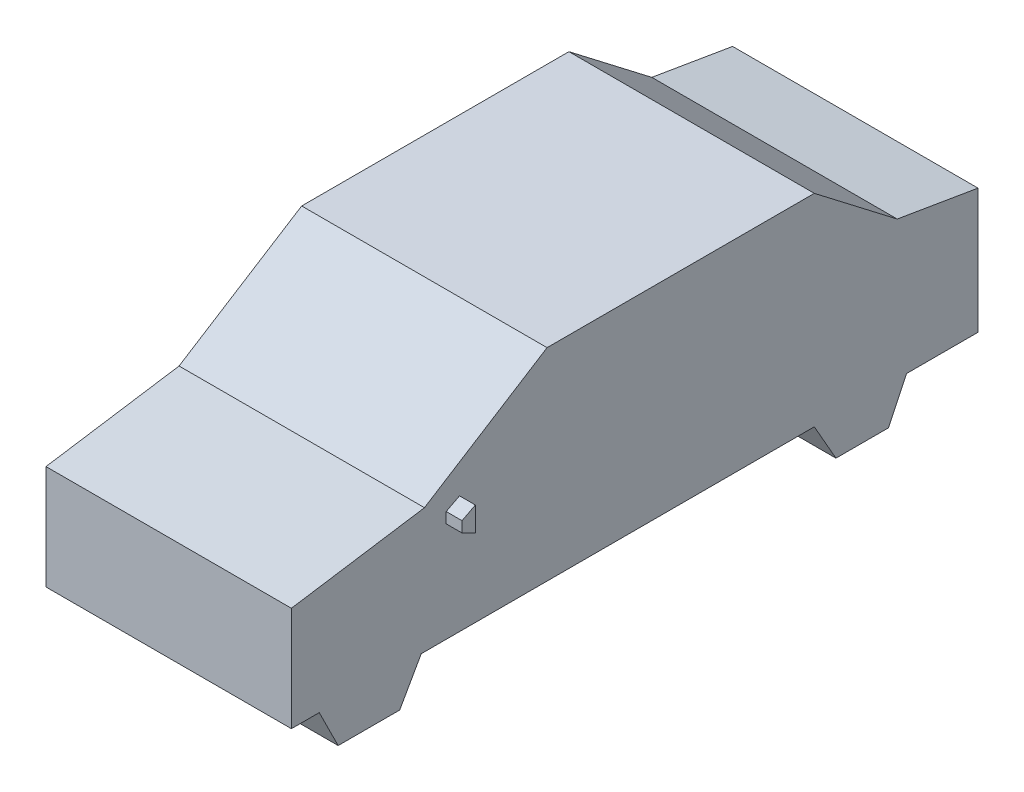
from build123d import *

# Parameters (mm, degrees)
EXTRUDE_1_DEPTH      = 1550
EXTRUDE_2_DEPTH      = 100
EXTRUDE_2_DEPTH_BACK = 1650


with BuildPart() as part:
    # Эскиз1 → Бобышка-Вытянуть1 (new body)
    with BuildSketch(Plane(origin=(0, 0, 0), x_dir=(0, 0, -1), z_dir=(1, 0, 0))):
        Polygon((0, 0), (0, 658.87563872), (840.441792245, 788.73141871), (1614.79322398, 1277), (3302.785099296, 1277), (3826.472113363, 874.659150999), (4336.637717029, 788.734761174), (4336.637717029, 0), (3886.057467004, 0), (3771.246676393, -240), (3439.453351147, -240), (3302.785099296, 0), (820.119296538, 0), (684.047248406, -240), (295.379400048, -240), (176.017340053, 0), align=None)
    extrude(amount=EXTRUDE_1_DEPTH)

    # Эскиз2 → Бобышка-Вытянуть2 (add, two sides)
    with BuildSketch(Plane(origin=(1550, 0, 0), x_dir=(0, 0, -1), z_dir=(1, 0, 0))) as extrude_2_sk:
        Polygon((977.680000946, 699.13622092), (977.680000946, 631.780006551), (1061.885264707, 590.645631586), (1061.885264707, 742.845049311), align=None)
    extrude(amount=EXTRUDE_2_DEPTH)
    extrude(extrude_2_sk.sketch, amount=-EXTRUDE_2_DEPTH_BACK)


solid = part.part
